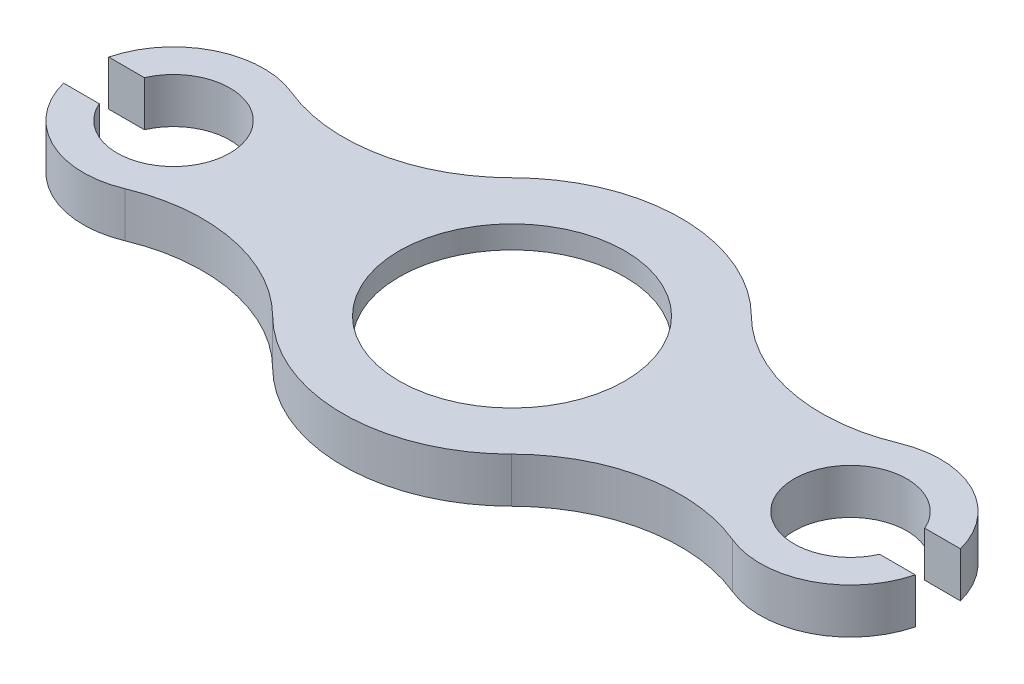
from build123d import *

# Parameters (mm, degrees)
BOSS_EXTRUDE1_DEPTH = 20
SKETCH2_R           = 50
CUT_EXTRUDE1_DEPTH  = 21
SKETCH3_R           = 67.8
CUT_EXTRUDE2_DEPTH  = 10


with BuildPart() as part:
    # Sketch1 → Boss-Extrude1 (new body)
    with BuildSketch(Plane(origin=(0, 0, 0), x_dir=(1, 0, 0), z_dir=(0, 1, 0))):
        with BuildLine():
            Line((-155.605186167, -46.133603239), (-171.422141154, -46.133603239))
            ThreePointArc((-171.422141154, -46.133603239), (-150.534652365, -71.933753191), (-117.358974359, -73.078005912))
            ThreePointArc((-117.358974359, -73.078005912), (-74.054836917, -68.774464575), (-35.650641026, -89.241182082))
            ThreePointArc((-35.650641026, -89.241182082), (17.307692308, -111.133603239), (70.266025641, -89.241182082))
            ThreePointArc((70.266025641, -89.241182082), (108.670221533, -68.774464575), (151.974358974, -73.078005912))
            ThreePointArc((151.974358974, -73.078005912), (185.150036981, -71.933753191), (206.03752577, -46.133603239))
            Line((206.03752577, -46.133603239), (190.220570782, -46.133603239))
            ThreePointArc((190.220570782, -46.133603239), (142.307692308, -36.133603239), (190.220570782, -26.133603239))
            Line((190.220570782, -26.133603239), (206.03752577, -26.133603239))
            ThreePointArc((206.03752577, -26.133603239), (185.150036981, -0.333453287), (151.974358974, 0.810799434))
            ThreePointArc((151.974358974, 0.810799434), (108.670221533, -3.492741903), (70.266025641, 16.973975604))
            ThreePointArc((70.266025641, 16.973975604), (17.307692308, 38.866396761), (-35.650641026, 16.973975604))
            ThreePointArc((-35.650641026, 16.973975604), (-74.054836917, -3.492741903), (-117.358974359, 0.810799434))
            ThreePointArc((-117.358974359, 0.810799434), (-150.534652365, -0.333453287), (-171.422141154, -26.133603239))
            Line((-171.422141154, -26.133603239), (-155.605186167, -26.133603239))
            ThreePointArc((-155.605186167, -26.133603239), (-107.692307692, -36.133603239), (-155.605186167, -46.133603239))
        make_face()
    extrude(amount=BOSS_EXTRUDE1_DEPTH)

    # Sketch2 → Cut-Extrude1 (cut, through all)
    with BuildSketch(Plane(origin=(0, 20, 0), x_dir=(1, 0, 0), z_dir=(0, 1, 0))):
        with Locations((17.307692308, -36.133603239)):
            Circle(SKETCH2_R)
    extrude(amount=-CUT_EXTRUDE1_DEPTH, mode=Mode.SUBTRACT)

    # Sketch3 → Cut-Extrude2 (cut)
    with BuildSketch(Plane.XZ):
        with Locations((17.307692308, 36.133603239)):
            Circle(SKETCH3_R)
    extrude(amount=-CUT_EXTRUDE2_DEPTH, mode=Mode.SUBTRACT)


solid = part.part
